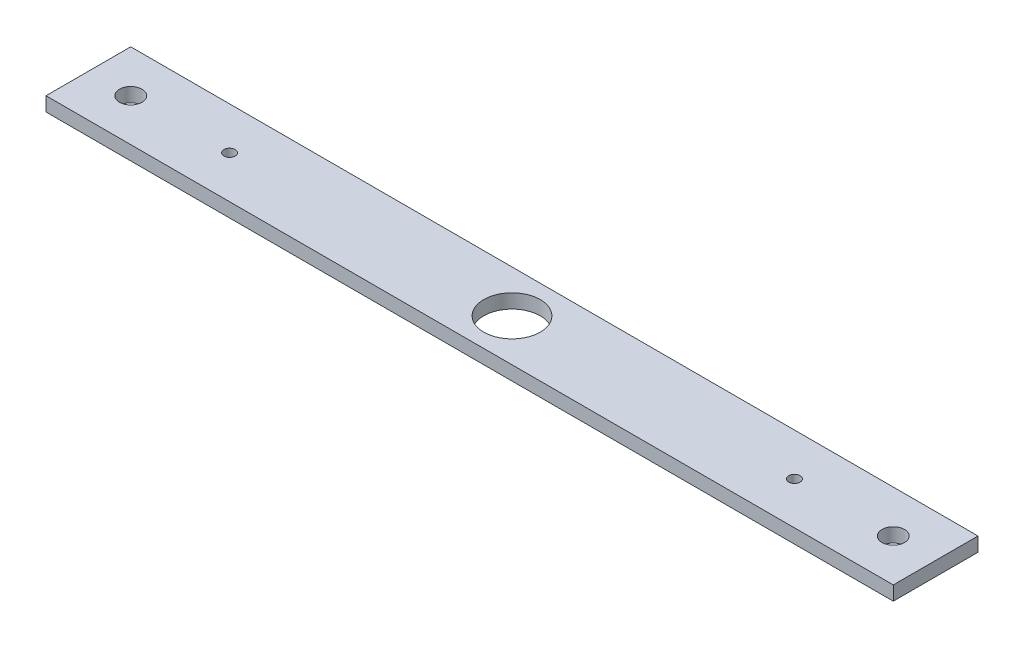
from build123d import *

# Parameters (mm, degrees)
SKETCH2_W           = 300
SKETCH2_H           = 30
BOSS_EXTRUDE1_DEPTH = 5
SKETCH3_R           = 4
SKETCH3_R_2         = 10
CUT_EXTRUDE1_DEPTH  = 5
SKETCH5_R           = 2
CUT_EXTRUDE2_DEPTH  = 5


with BuildPart() as part:
    # Sketch2 → Boss-Extrude1 (new body)
    with BuildSketch(Plane(origin=(0, 0, 0), x_dir=(1, 0, 0), z_dir=(0, 1, 0))):
        Rectangle(SKETCH2_W, SKETCH2_H)
    extrude(amount=BOSS_EXTRUDE1_DEPTH)

    # Sketch3 → Cut-Extrude1 (cut)
    with BuildSketch(Plane(origin=(0, 5, 0), x_dir=(1, 0, 0), z_dir=(0, 1, 0))):
        with Locations((-135, 0)):
            Circle(SKETCH3_R)
        Circle(SKETCH3_R_2)
        with Locations((135, 0)):
            Circle(SKETCH3_R)
    extrude(amount=-CUT_EXTRUDE1_DEPTH, mode=Mode.SUBTRACT)

    # Sketch5 → Cut-Extrude2 (cut)
    with BuildSketch(Plane(origin=(0, 5, 0), x_dir=(1, 0, 0), z_dir=(0, 1, 0))):
        with Locations((100, 0)):
            Circle(SKETCH5_R)
        with Locations((-100, 0)):
            Circle(SKETCH5_R)
    extrude(amount=-CUT_EXTRUDE2_DEPTH, mode=Mode.SUBTRACT)


solid = part.part
